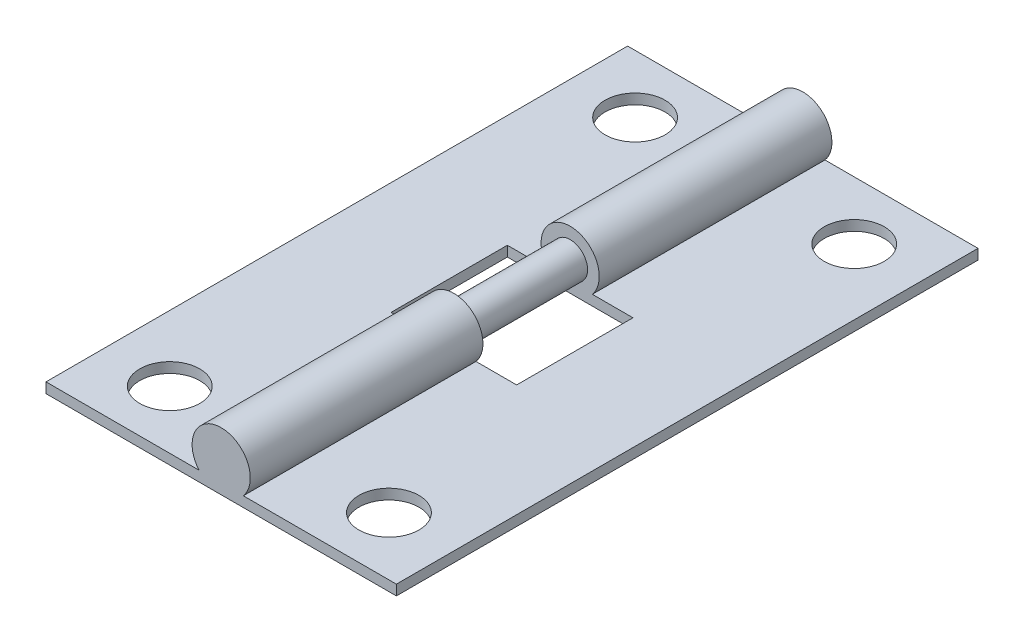
from build123d import *

# Parameters (mm, degrees)
BOSS_EXTRUDE1_DEPTH = 31.75
SKETCH3_W           = 6.858
SKETCH3_H           = 6.35
SKETCH3_R           = 1.6383
CUT_EXTRUDE1_DEPTH  = 4.175
BOSS_EXTRUDE2_REACH = 21.05
SKETCH4_R           = 0.9525


with BuildPart() as part:
    # Sketch1 → Boss-Extrude1 (new body)
    with BuildSketch(Plane.XY):
        with BuildLine():
            Line((0, 0), (19.1262, 0))
            Line((19.1262, 0), (19.1262, 0.5588))
            Line((19.1262, 0.5588), (10.772204032, 0.5588))
            ThreePointArc((10.772204032, 0.5588), (9.5631, 3.175), (8.353995968, 0.5588))
            Line((8.353995968, 0.5588), (0, 0.5588))
            Line((0, 0.5588), (0, 0))
        make_face()
    extrude(amount=BOSS_EXTRUDE1_DEPTH)

    # Sketch3 → Cut-Extrude1 (cut, through all)
    with BuildSketch(Plane.XZ):
        with Locations((9.5631, 15.875)):
            Rectangle(SKETCH3_W, SKETCH3_H)
        with Locations((3.5814, 28.575)):
            Circle(SKETCH3_R)
        with Locations((15.5448, 28.575)):
            Circle(SKETCH3_R)
        with Locations((15.5448, 3.175)):
            Circle(SKETCH3_R)
        with Locations((3.5814, 3.175)):
            Circle(SKETCH3_R)
    extrude(amount=-CUT_EXTRUDE1_DEPTH, mode=Mode.SUBTRACT)

    # Sketch4 → Boss-Extrude2 (add, up to next)
    with BuildSketch(Plane.XY.offset(12.7), mode=Mode.PRIVATE) as boss_extrude2_sk1:
        with Locations((9.5631, 1.5875)):
            Circle(SKETCH4_R)
    boss_extrude2_tool1 = extrude(boss_extrude2_sk1.sketch, amount=BOSS_EXTRUDE2_REACH, mode=Mode.PRIVATE) - part.part
    add(boss_extrude2_tool1.solids().sort_by_distance((9.5631, 1.5875, 12.7))[0])


solid = part.part
